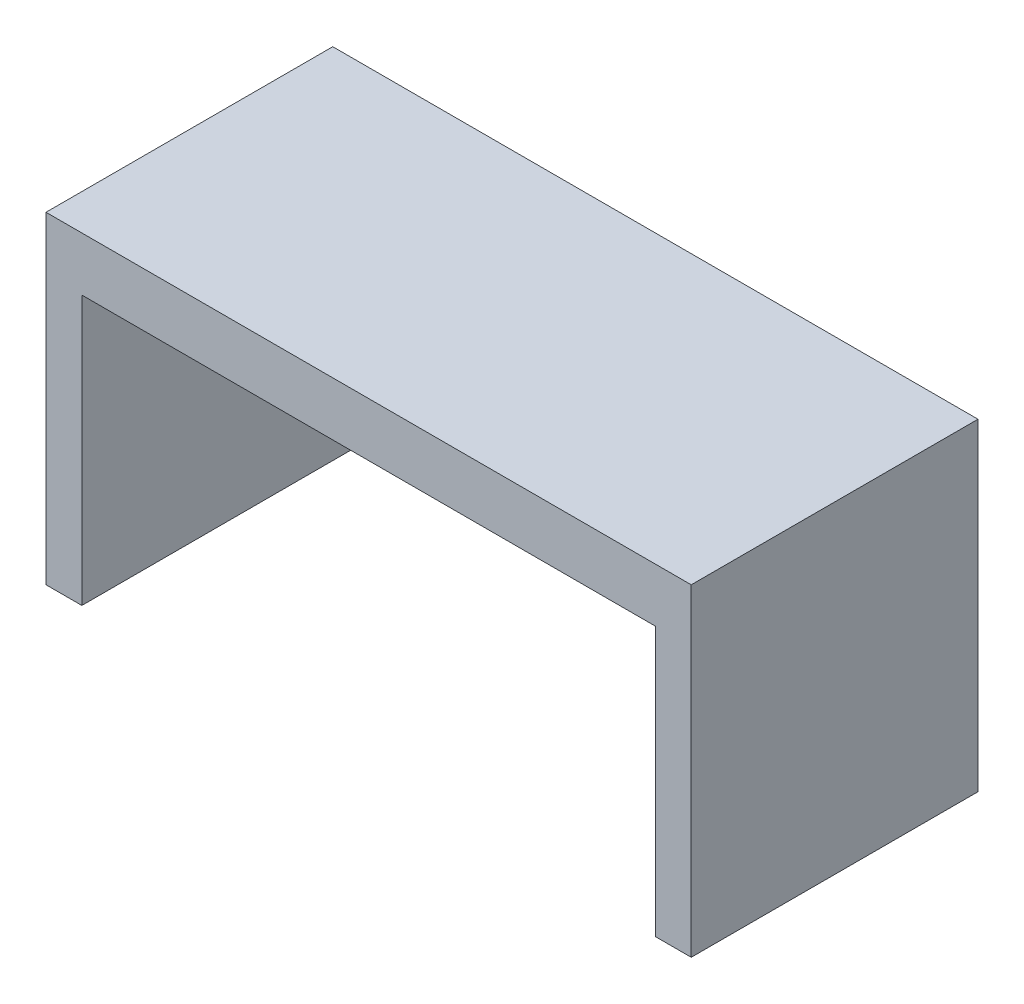
from build123d import *

# Parameters (mm, degrees)
SKETCH1_W           = 1800
SKETCH1_H           = 800
BOSS_EXTRUDE1_DEPTH = 900
SKETCH2_W           = 1600
SKETCH2_H           = 750
CUT_EXTRUDE1_DEPTH  = 1200
SKETCH3_R           = 22.236476972
BOSS_EXTRUDE2_DEPTH = 20


with BuildPart() as part:
    # Sketch1 → Boss-Extrude1 (new body)
    with BuildSketch(Plane(origin=(0, 0, 0), x_dir=(1, 0, 0), z_dir=(0, 1, 0))):
        with Locations((-3.06122449, -127.551020408)):
            Rectangle(SKETCH1_W, SKETCH1_H)
    extrude(amount=BOSS_EXTRUDE1_DEPTH)

    # Sketch2 → Cut-Extrude1 (cut)
    with BuildSketch(Plane.XY.offset(527.551020408)):
        with Locations((-3.06122449, 375)):
            Rectangle(SKETCH2_W, SKETCH2_H)
    extrude(amount=-CUT_EXTRUDE1_DEPTH, mode=Mode.SUBTRACT)


with BuildPart() as body_2:
    # Sketch3 → Boss-Extrude2 (new body)
    with BuildSketch(Plane.XZ.offset(-750)):
        with Locations((-3.06122449, 77.551020408)):
            Circle(SKETCH3_R)
    extrude(amount=BOSS_EXTRUDE2_DEPTH)


solid = Compound([part.part, body_2.part])
